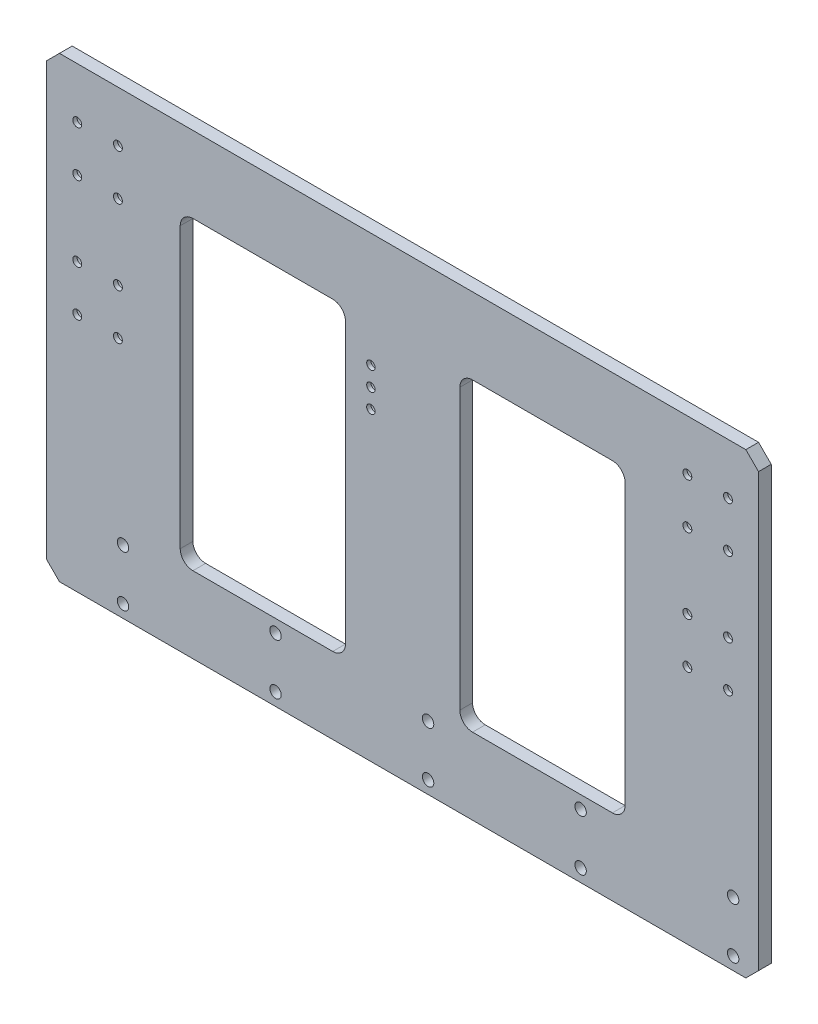
from build123d import *

# Parameters (mm, degrees)
SKETCH_1_R                = 3.5
SKETCH_1_R_2              = 4.5
SKETCH_1_R_3              = 1.5
EXTRUDE_1_DEPTH           = 10
HOLE_WIZARD_1_D           = 6.6
HOLE_WIZARD_1_DEPTH       = 18
HOLE_WIZARD_1_CBORE_D     = 11
HOLE_WIZARD_1_CBORE_DEPTH = 6.8
HOLE_WIZARD_1_TIP         = 1.982840043


with BuildPart() as part:
    # 草图1 → 凸台-拉伸1 (new body)
    with BuildSketch(Plane.XY):
        Polygon((-270, 180), (270, 180), (280, 170), (280, -170), (270, -180), (-270, -180), (-280, -170), (-280, 170), align=None)
        with Locations((-256, 140)):
            Circle(SKETCH_1_R, mode=Mode.SUBTRACT)
        with Locations((-224, 140)):
            Circle(SKETCH_1_R, mode=Mode.SUBTRACT)
        with Locations((-256, 104)):
            Circle(SKETCH_1_R, mode=Mode.SUBTRACT)
        with Locations((-224, 104)):
            Circle(SKETCH_1_R, mode=Mode.SUBTRACT)
        with Locations((256, 104)):
            Circle(SKETCH_1_R, mode=Mode.SUBTRACT)
        with Locations((224, 104)):
            Circle(SKETCH_1_R, mode=Mode.SUBTRACT)
        with Locations((224, 140)):
            Circle(SKETCH_1_R, mode=Mode.SUBTRACT)
        with Locations((256, 140)):
            Circle(SKETCH_1_R, mode=Mode.SUBTRACT)
        with Locations((-220, -130)):
            Circle(SKETCH_1_R_2, mode=Mode.SUBTRACT)
        with Locations((-100, -130)):
            Circle(SKETCH_1_R_2, mode=Mode.SUBTRACT)
        with Locations((20, -130)):
            Circle(SKETCH_1_R_2, mode=Mode.SUBTRACT)
        with Locations((140, -130)):
            Circle(SKETCH_1_R_2, mode=Mode.SUBTRACT)
        with Locations((260, -130)):
            Circle(SKETCH_1_R_2, mode=Mode.SUBTRACT)
        with Locations((-100, -170)):
            Circle(SKETCH_1_R_2, mode=Mode.SUBTRACT)
        with Locations((20, -170)):
            Circle(SKETCH_1_R_2, mode=Mode.SUBTRACT)
        with Locations((140, -170)):
            Circle(SKETCH_1_R_2, mode=Mode.SUBTRACT)
        with Locations((260, -170)):
            Circle(SKETCH_1_R_2, mode=Mode.SUBTRACT)
        with Locations((-220, -170)):
            Circle(SKETCH_1_R_2, mode=Mode.SUBTRACT)
        with Locations((-25, 90)):
            Circle(SKETCH_1_R_3, mode=Mode.SUBTRACT)
        with Locations((-256, 45)):
            Circle(SKETCH_1_R, mode=Mode.SUBTRACT)
        with Locations((-224, 45)):
            Circle(SKETCH_1_R, mode=Mode.SUBTRACT)
        with Locations((-25, 75)):
            Circle(SKETCH_1_R_3, mode=Mode.SUBTRACT)
        with Locations((-25, 60)):
            Circle(SKETCH_1_R_3, mode=Mode.SUBTRACT)
        with Locations((-256, 9)):
            Circle(SKETCH_1_R, mode=Mode.SUBTRACT)
        with Locations((-224, 9)):
            Circle(SKETCH_1_R, mode=Mode.SUBTRACT)
        with Locations((224, 45)):
            Circle(SKETCH_1_R, mode=Mode.SUBTRACT)
        with Locations((256, 45)):
            Circle(SKETCH_1_R, mode=Mode.SUBTRACT)
        with Locations((224, 9)):
            Circle(SKETCH_1_R, mode=Mode.SUBTRACT)
        with Locations((256, 9)):
            Circle(SKETCH_1_R, mode=Mode.SUBTRACT)
        with BuildLine():
            Line((-165, 120), (-55, 120))
            ThreePointArc((-55, 120), (-47.928932188, 117.071067812), (-45, 110))
            Line((-45, 110), (-45, -110))
            ThreePointArc((-45, -110), (-47.928932188, -117.071067812), (-55, -120))
            Line((-55, -120), (-165, -120))
            ThreePointArc((-165, -120), (-172.071067812, -117.071067812), (-175, -110))
            Line((-175, -110), (-175, 110))
            ThreePointArc((-175, 110), (-172.071067812, 117.071067812), (-165, 120))
        make_face(mode=Mode.SUBTRACT)
        with BuildLine():
            Line((165, -120), (55, -120))
            ThreePointArc((55, -120), (47.928932188, -117.071067812), (45, -110))
            Line((45, -110), (45, 110))
            ThreePointArc((45, 110), (47.928932188, 117.071067812), (55, 120))
            Line((55, 120), (165, 120))
            ThreePointArc((165, 120), (172.071067812, 117.071067812), (175, 110))
            Line((175, 110), (175, -110))
            ThreePointArc((175, -110), (172.071067812, -117.071067812), (165, -120))
        make_face(mode=Mode.SUBTRACT)
    extrude(amount=EXTRUDE_1_DEPTH)

    # 打孔尺寸(%根据)内六角圆柱头螺钉的类型1
    with Locations(Plane(origin=(-256, 9, 0), x_dir=(-1, 0, 0), z_dir=(0, 0, -1))):
        with Locations((0, 0), (-480, 131), (-512, 131), (-512, 95), (-480, 95), (-512, 36), (-480, 36), (-512, 0), (-480, 0), (-231, 81), (-231, 66), (-231, 51), (-32, 131), (-32, 95), (0, 95), (0, 131), (-32, 36), (0, 36), (-32, 0)):
            CounterBoreHole(HOLE_WIZARD_1_D / 2, HOLE_WIZARD_1_CBORE_D / 2, HOLE_WIZARD_1_CBORE_DEPTH, depth=HOLE_WIZARD_1_DEPTH)
            with Locations((0, 0, -(HOLE_WIZARD_1_DEPTH + HOLE_WIZARD_1_TIP / 2))):  # 118° drill point
                Cone(0, HOLE_WIZARD_1_D / 2, HOLE_WIZARD_1_TIP, mode=Mode.SUBTRACT)


solid = part.part
